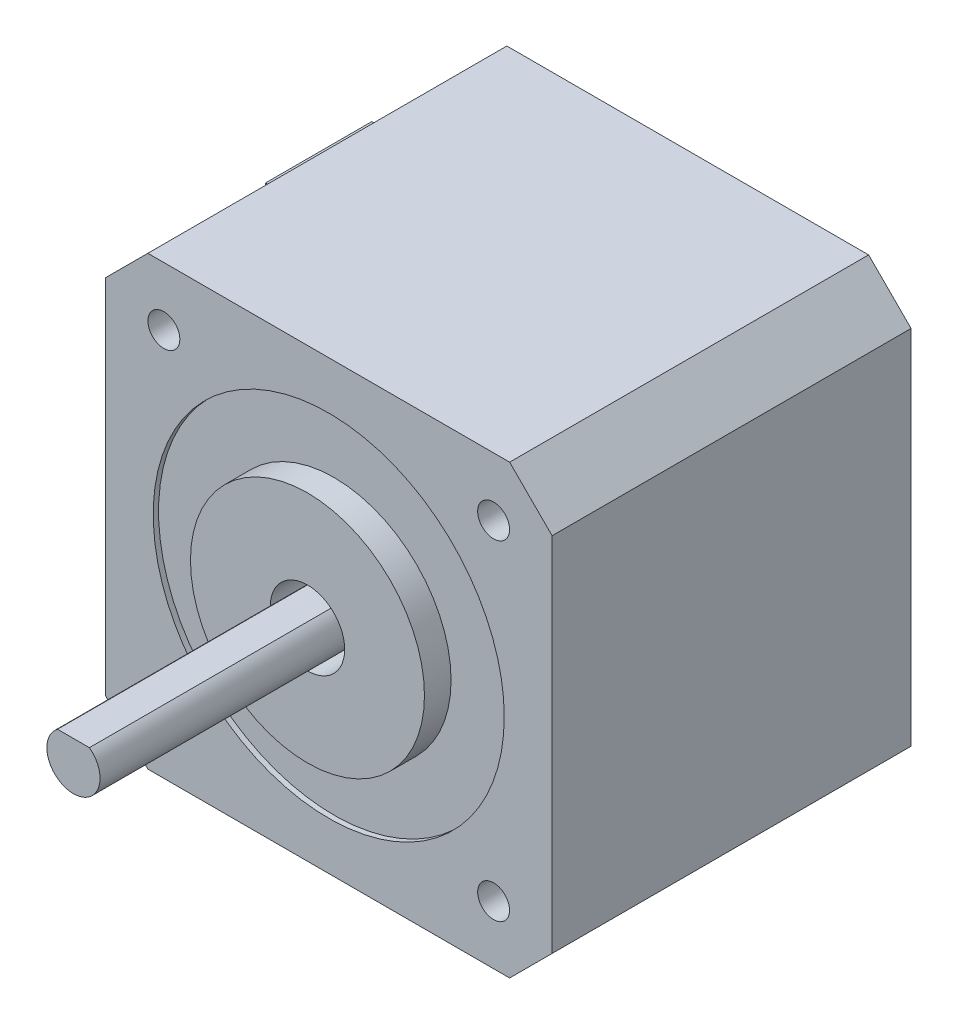
from build123d import *

# Parameters (mm, degrees)
BOSS_EXTRUDE1_DEPTH = 33.75
SKETCH2_R           = 16.5
CUT_EXTRUDE1_DEPTH  = 0.5
SKETCH3_R           = 11
BOSS_EXTRUDE2_DEPTH = 2.5
SKETCH4_R           = 3.5
CUT_EXTRUDE2_DEPTH  = 5
BOSS_EXTRUDE3_DEPTH = 27
SKETCH6_R           = 1.5
CUT_EXTRUDE3_DEPTH  = 5
SKETCH7_W           = 10
SKETCH7_H           = 17
BOSS_EXTRUDE4_DEPTH = 8.7


with BuildPart() as part:
    # Sketch1 → Boss-Extrude1 (new body)
    with BuildSketch(Plane.XY):
        Polygon((-17.006989489, 21), (-21, 17.006989489), (-21, -17.006989489), (-17.006989489, -21), (17.006989489, -21), (21, -17.006989489), (21, 17.006989489), (17.006989489, 21), align=None)
    extrude(amount=BOSS_EXTRUDE1_DEPTH)

    # Sketch2 → Cut-Extrude1 (cut)
    with BuildSketch(Plane.XY.offset(33.75)):
        Circle(SKETCH2_R)
    extrude(amount=-CUT_EXTRUDE1_DEPTH, mode=Mode.SUBTRACT)

    # Sketch3 → Boss-Extrude2 (add)
    with BuildSketch(Plane.XY.offset(33.25)):
        Circle(SKETCH3_R)
    extrude(amount=BOSS_EXTRUDE2_DEPTH)

    # Sketch4 → Cut-Extrude2 (cut)
    with BuildSketch(Plane.XY.offset(35.75)):
        Circle(SKETCH4_R)
    extrude(amount=-CUT_EXTRUDE2_DEPTH, mode=Mode.SUBTRACT)

    # Sketch5 → Boss-Extrude3 (add)
    with BuildSketch(Plane.XY.offset(30.75)):
        with BuildLine():
            Line((-1.5, 2), (1.5, 2))
            ThreePointArc((1.5, 2), (0, -2.5), (-1.5, 2))
        make_face()
    extrude(amount=BOSS_EXTRUDE3_DEPTH)

    # Sketch6 → Cut-Extrude3 (cut)
    with BuildSketch(Plane.XY.offset(33.75)):
        with Locations((-15.5, 15.5)):
            Circle(SKETCH6_R)
        with Locations((15.5, 15.5)):
            Circle(SKETCH6_R)
        with Locations((15.5, -15.5)):
            Circle(SKETCH6_R)
        with Locations((-15.5, -15.5)):
            Circle(SKETCH6_R)
    cut_extrude3 = extrude(amount=-CUT_EXTRUDE3_DEPTH, mode=Mode.SUBTRACT)

    # Mirror1: Cut-Extrude3 across plane
    add(cut_extrude3.mirror(Plane(origin=(0, 0, 16.875), x_dir=(1, 0, 0), z_dir=(0, 0, -1))), mode=Mode.SUBTRACT)

    # Sketch7 → Boss-Extrude4 (add)
    with BuildSketch(Plane.ZY.offset(21)):
        with Locations((5, 0)):
            Rectangle(SKETCH7_W, SKETCH7_H)
    extrude(amount=BOSS_EXTRUDE4_DEPTH)


solid = part.part
